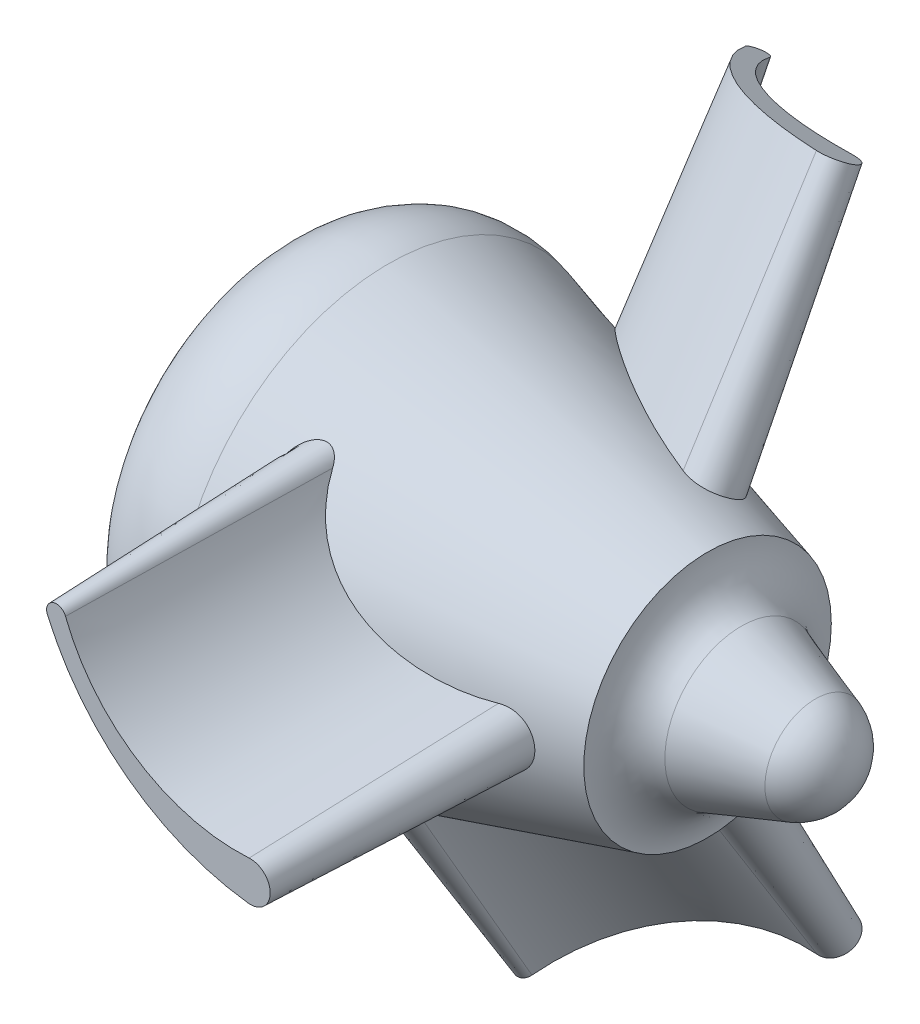
from build123d import *

# Parameters (mm, degrees)
BOSS_EXTRUDE6_DEPTH = 350
BOSS_EXTRUDE6_TAPER = 2
CIRPATTERN1_COUNT   = 3


with BuildPart() as part:
    # Croquis1 → Revolución1 (revolve)
    with BuildSketch(Plane.XY):
        with BuildLine():
            Line((0, 111), (0, 0))
            Line((0, 0), (522, 0))
            ThreePointArc((522, 0), (513.123486868, 27.809221049), (489.776967695, 45.333070604))
            Line((489.776967695, 45.333070604), (423.209092786, 68.500246309))
            ThreePointArc((423.209092786, 68.500246309), (401.321731062, 84.928855267), (393, 111))
            Line((393, 111), (106.834951456, 191.83665624))
            ThreePointArc((106.834951456, 191.83665624), (33.315366837, 177.985580248), (0, 111))
        make_face()
    revolve(axis=Axis((0, 0, 0), (1, 0, 0)))

    # Croquis3 → Boss-Extrude6 (add)
    with BuildSketch(Plane.XY):
        with BuildLine():
            ThreePointArc((139.717966312, 111.681155318), (215.670803552, 15.560478766), (329.473987048, -29.792066606))
            ThreePointArc((329.473987048, -29.792066606), (362.989050359, -0.810468103), (331.08824771, 29.939024753))
            ThreePointArc((331.08824771, 29.939024753), (238.849734138, 53.769078929), (178.59255478, 127.558557879))
            ThreePointArc((178.59255478, 127.558557879), (151.059780617, 139.441011191), (139.717966312, 111.681155318))
        make_face()
    boss_extrude6 = extrude(amount=BOSS_EXTRUDE6_DEPTH, taper=BOSS_EXTRUDE6_TAPER)

    # CirPattern1: Boss-Extrude6 ×3 about axis
    cirpattern1_axis = Axis((0, 0, 0), (1, 0, 0))
    for i in range(1, CIRPATTERN1_COUNT):
        add(boss_extrude6.rotate(cirpattern1_axis, i * 360 / CIRPATTERN1_COUNT))


solid = part.part
